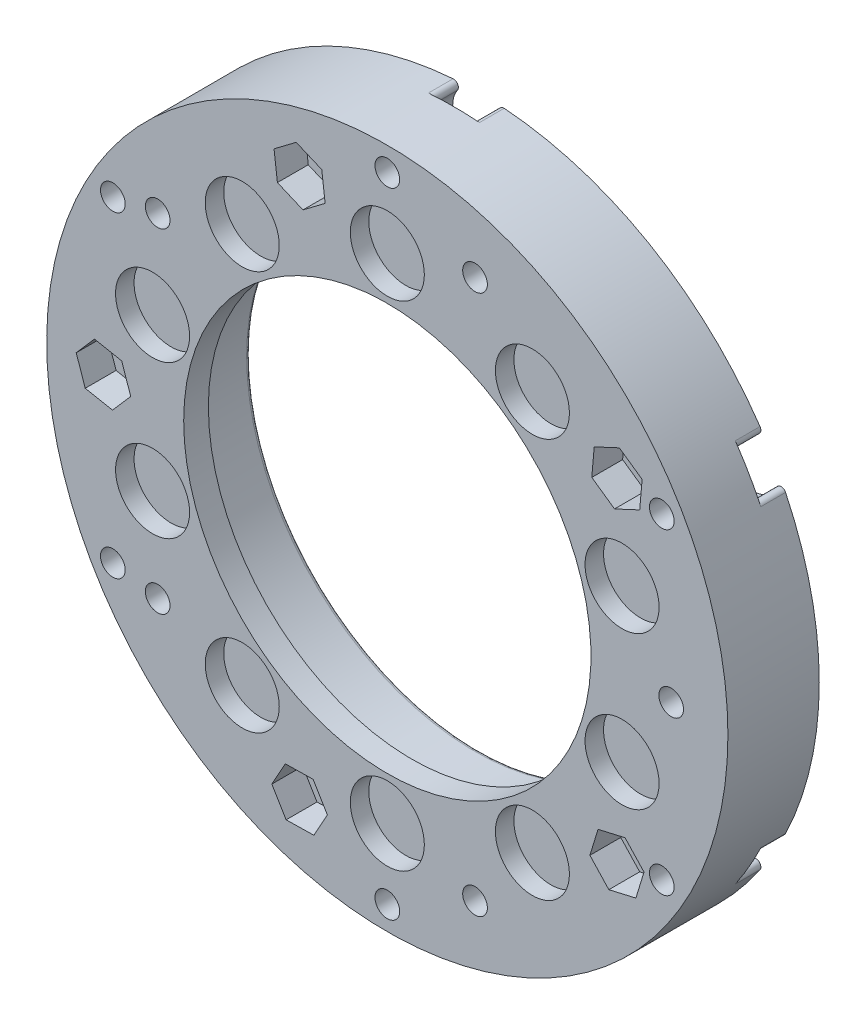
from build123d import *

# Parameters (mm, degrees)
SKETCH_1_R                = 27.6
EXTRUDE_1_DEPTH           = 5.5
SKETCH_2_R                = 3
CUT_EXTRUDE_1_DEPTH       = 1.5
SKETCH_5_R                = 18.5
CUT_EXTRUDE_3_DEPTH       = 3.5
SKETCH_7_R                = 16.5
CUT_EXTRUDE_8_DEPTH       = 4.5
CUT_EXTRUDE_8_DEPTH_BACK  = 3
SKETCH_8_R                = 27.6
SKETCH_8_R_2              = 18.5
EXTRUDE_3_DEPTH           = 0.5
SKETCH_9_R                = 1
CUT_EXTRUDE_9_DEPTH       = 1
CUT_EXTRUDE_9_DEPTH_BACK  = 7
SKETCH_10_R               = 27.6
SKETCH_10_R_2             = 18.5
SKETCH_10_R_3             = 1
EXTRUDE_4_DEPTH           = 1.4
SKETCH_11_R               = 1
EXTRUDE_5_DEPTH           = 7.4
SKETCH_12_R               = 1
CUT_EXTRUDE_10_DEPTH      = 8.4
CUT_EXTRUDE_11_DEPTH      = 2
SKETCH_15_R               = 1
CUT_EXTRUDE_12_DEPTH      = 3
CUT_EXTRUDE_12_DEPTH_BACK = 6.4
SKETCH_16_R               = 1
CUT_EXTRUDE_13_DEPTH      = 1
CUT_EXTRUDE_13_DEPTH_BACK = 8.4
SKETCH_18_R               = 1
EXTRUDE_6_DEPTH           = 2
CUT_EXTRUDE_15_DEPTH      = 2.5
SKETCH_20_R               = 2.1
CUT_EXTRUDE_16_DEPTH      = 2
FILLET_2_R                = 0.4
SKETCH_21_R               = 1.9
CUT_EXTRUDE_17_DEPTH      = 2
FILLET_3_R                = 0.3
FILLET_4_R                = 0.3


with BuildPart() as part:
    # 草图1 → 凸台-拉伸1 (new body)
    with BuildSketch(Plane.XY):
        Circle(SKETCH_1_R)
    extrude(amount=EXTRUDE_1_DEPTH)

    # 草图2 → 切除-拉伸1 (cut)
    with BuildSketch(Plane.XY.offset(5.5)):
        with Locations((0, 20)):
            Circle(SKETCH_2_R)
        with Locations((11.755705046, 16.180339887)):
            Circle(SKETCH_2_R)
        with Locations((19.021130326, 6.180339887)):
            Circle(SKETCH_2_R)
        with Locations((19.021130326, -6.180339887)):
            Circle(SKETCH_2_R)
        with Locations((11.755705046, -16.180339887)):
            Circle(SKETCH_2_R)
        with Locations((0, -20)):
            Circle(SKETCH_2_R)
        with Locations((-11.755705046, -16.180339887)):
            Circle(SKETCH_2_R)
        with Locations((-19.021130326, -6.180339887)):
            Circle(SKETCH_2_R)
        with Locations((-19.021130326, 6.180339887)):
            Circle(SKETCH_2_R)
        with Locations((-11.755705046, 16.180339887)):
            Circle(SKETCH_2_R)
    extrude(amount=-CUT_EXTRUDE_1_DEPTH, mode=Mode.SUBTRACT)

    # 草图5 → 切除-拉伸3 (cut)
    with BuildSketch(Plane(origin=(0, 0, 0), x_dir=(-1, 0, 0), z_dir=(0, 0, -1))):
        Circle(SKETCH_5_R)
    extrude(amount=-CUT_EXTRUDE_3_DEPTH, mode=Mode.SUBTRACT)

    # 草图7 → 切除-拉伸8 (cut, two sides)
    with BuildSketch(Plane(origin=(0, 0, 3.5), x_dir=(-1, 0, 0), z_dir=(0, 0, -1))) as cut_extrude_8_sk:
        Circle(SKETCH_7_R)
    extrude(amount=CUT_EXTRUDE_8_DEPTH, mode=Mode.SUBTRACT)
    extrude(cut_extrude_8_sk.sketch, amount=-CUT_EXTRUDE_8_DEPTH_BACK, mode=Mode.SUBTRACT)

    # 草图8 → 凸台-拉伸3 (add)
    with BuildSketch(Plane(origin=(0, 0, 0), x_dir=(-1, 0, 0), z_dir=(0, 0, -1))):
        Circle(SKETCH_8_R)
        Circle(SKETCH_8_R_2, mode=Mode.SUBTRACT)
    extrude(amount=EXTRUDE_3_DEPTH)

    # 草图9 → 切除-拉伸9 (cut, two sides)
    with BuildSketch(Plane.XY.offset(5.5)) as cut_extrude_9_sk:
        with Locations((8.546820623, 24.215991766)):
            Circle(SKETCH_9_R)
        with Locations((25.245074359, 4.706232102)):
            Circle(SKETCH_9_R)
        with Locations((16.698253736, -19.509759665)):
            Circle(SKETCH_9_R)
        with Locations((-8.546820623, -24.215991766)):
            Circle(SKETCH_9_R)
        with Locations((-25.245074359, -4.706232102)):
            Circle(SKETCH_9_R)
        with Locations((-16.698253736, 19.509759665)):
            Circle(SKETCH_9_R)
    extrude(amount=CUT_EXTRUDE_9_DEPTH, mode=Mode.SUBTRACT)
    extrude(cut_extrude_9_sk.sketch, amount=-CUT_EXTRUDE_9_DEPTH_BACK, mode=Mode.SUBTRACT)

    # 草图10 → 凸台-拉伸4 (add)
    with BuildSketch(Plane(origin=(0, 0, -0.5), x_dir=(-1, 0, 0), z_dir=(0, 0, -1))):
        Circle(SKETCH_10_R)
        Circle(SKETCH_10_R_2, mode=Mode.SUBTRACT)
        with Locations((-8.546820623, 24.215991766)):
            Circle(SKETCH_10_R_3, mode=Mode.SUBTRACT)
        with Locations((16.698253736, 19.509759665)):
            Circle(SKETCH_10_R_3, mode=Mode.SUBTRACT)
        with Locations((25.245074359, -4.706232102)):
            Circle(SKETCH_10_R_3, mode=Mode.SUBTRACT)
        with Locations((8.546820623, -24.215991766)):
            Circle(SKETCH_10_R_3, mode=Mode.SUBTRACT)
        with Locations((-16.698253736, -19.509759665)):
            Circle(SKETCH_10_R_3, mode=Mode.SUBTRACT)
        with Locations((-25.245074359, 4.706232102)):
            Circle(SKETCH_10_R_3, mode=Mode.SUBTRACT)
    extrude(amount=EXTRUDE_4_DEPTH)

    # 草图11 → 凸台-拉伸5 (add)
    with BuildSketch(Plane.XY.offset(5.5)):
        with Locations((8.546820623, 24.215991766)):
            Circle(SKETCH_11_R)
        with Locations((25.245074359, 4.706232102)):
            Circle(SKETCH_11_R)
        with Locations((16.698253736, -19.509759665)):
            Circle(SKETCH_11_R)
        with Locations((-8.546820623, -24.215991766)):
            Circle(SKETCH_11_R)
        with Locations((-25.245074359, -4.706232102)):
            Circle(SKETCH_11_R)
        with Locations((-16.698253736, 19.509759665)):
            Circle(SKETCH_11_R)
    extrude(amount=-EXTRUDE_5_DEPTH)

    # 草图12 → 切除-拉伸10 (cut, through all)
    with BuildSketch(Plane.XY.offset(5.5)):
        with Locations((0, 25.68)):
            Circle(SKETCH_12_R)
        with Locations((22.239532369, 12.84)):
            Circle(SKETCH_12_R)
        with Locations((22.239532369, -12.84)):
            Circle(SKETCH_12_R)
        with Locations((0, -25.68)):
            Circle(SKETCH_12_R)
        with Locations((-22.239532369, -12.84)):
            Circle(SKETCH_12_R)
        with Locations((-22.239532369, 12.84)):
            Circle(SKETCH_12_R)
    extrude(amount=-CUT_EXTRUDE_10_DEPTH, mode=Mode.SUBTRACT)

    # 草图13 → 切除-拉伸11 (cut)
    with BuildSketch(Plane.XY.offset(5.5)):
        Polygon((7.107390871, 24.124299875), (9.055948029, 22.999299875), (9.055948029, 20.749299875), (7.107390871, 19.624299875), (5.158833712, 20.749299875), (5.158833712, 22.999299875), align=None)
        Polygon((23.467801304, 2.200832102), (25.139877162, 0.695288237), (24.672075857, -1.505543864), (22.532198696, -2.200832102), (20.860122838, -0.695288237), (21.327924143, 1.505543864), align=None)
        Polygon((9.345065135, -21.639110832), (8.429907688, -23.694588112), (6.192233424, -23.929777154), (4.869716606, -22.109488917), (5.784874053, -20.054011637), (8.022548318, -19.818822595), align=None)
        Polygon((-17.692233424, -15.574538082), (-19.929907688, -15.33934904), (-20.845065135, -13.28387176), (-19.522548318, -11.463583523), (-17.284874053, -11.698772565), (-16.369716606, -13.754249845), align=None)
        Polygon((-20.279466728, 12.013516938), (-20.747268032, 14.21434904), (-19.075192175, 15.719892904), (-16.935315013, 15.024604667), (-16.467513709, 12.823772565), (-18.139589566, 11.318228701), align=None)
    extrude(amount=-CUT_EXTRUDE_11_DEPTH, mode=Mode.SUBTRACT)

    # 草图15 → 切除-拉伸12 (cut, two sides)
    with BuildSketch(Plane.XY.offset(3.5)) as cut_extrude_12_sk:
        with Locations((-18.607390871, 13.519060803)):
            Circle(SKETCH_15_R)
        with Locations((7.107390871, 21.874299875)):
            Circle(SKETCH_15_R)
        with Locations((23, 0)):
            Circle(SKETCH_15_R)
        with Locations((7.107390871, -21.874299875)):
            Circle(SKETCH_15_R)
        with Locations((-18.607390871, -13.519060803)):
            Circle(SKETCH_15_R)
    extrude(amount=CUT_EXTRUDE_12_DEPTH, mode=Mode.SUBTRACT)
    extrude(cut_extrude_12_sk.sketch, amount=-CUT_EXTRUDE_12_DEPTH_BACK, mode=Mode.SUBTRACT)

    # 草图16 → 切除-拉伸13 (cut, two sides)
    with BuildSketch(Plane.XY.offset(5.5)) as cut_extrude_13_sk:
        with Locations((-7.107390871, 21.874299875)):
            Circle(SKETCH_16_R)
        with Locations((18.607390871, 13.519060803)):
            Circle(SKETCH_16_R)
        with Locations((18.607390871, -13.519060803)):
            Circle(SKETCH_16_R)
        with Locations((-7.107390871, -21.874299875)):
            Circle(SKETCH_16_R)
        with Locations((-23, 0)):
            Circle(SKETCH_16_R)
    extrude(amount=CUT_EXTRUDE_13_DEPTH, mode=Mode.SUBTRACT)
    extrude(cut_extrude_13_sk.sketch, amount=-CUT_EXTRUDE_13_DEPTH_BACK, mode=Mode.SUBTRACT)

    # 草图18 → 凸台-拉伸6 (add)
    with BuildSketch(Plane.XY.offset(5.5)):
        Polygon((7.107390871, 24.124299875), (9.055948029, 22.999299875), (9.055948029, 20.749299875), (7.107390871, 19.624299875), (5.158833712, 20.749299875), (5.158833712, 22.999299875), align=None)
        with Locations((7.107390871, 21.874299875)):
            Circle(SKETCH_18_R, mode=Mode.SUBTRACT)
        Polygon((23.467801304, 2.200832102), (25.139877162, 0.695288237), (24.672075857, -1.505543864), (22.532198696, -2.200832102), (20.860122838, -0.695288237), (21.327924143, 1.505543864), align=None)
        with Locations((23, 0)):
            Circle(SKETCH_18_R, mode=Mode.SUBTRACT)
        Polygon((9.345065135, -21.639110832), (8.429907688, -23.694588112), (6.192233424, -23.929777154), (4.869716606, -22.109488917), (5.784874053, -20.054011637), (8.022548318, -19.818822595), align=None)
        with Locations((7.107390871, -21.874299875)):
            Circle(SKETCH_18_R, mode=Mode.SUBTRACT)
        Polygon((-17.692233424, -15.574538082), (-19.929907688, -15.33934904), (-20.845065135, -13.28387176), (-19.522548318, -11.463583523), (-17.284874053, -11.698772565), (-16.369716606, -13.754249845), align=None)
        with Locations((-18.607390871, -13.519060803)):
            Circle(SKETCH_18_R, mode=Mode.SUBTRACT)
        Polygon((-20.279466728, 12.013516938), (-20.747268032, 14.21434904), (-19.075192175, 15.719892904), (-16.935315013, 15.024604667), (-16.467513709, 12.823772565), (-18.139589566, 11.318228701), align=None)
        with Locations((-18.607390871, 13.519060803)):
            Circle(SKETCH_18_R, mode=Mode.SUBTRACT)
    extrude(amount=-EXTRUDE_6_DEPTH)

    # 草图19 → 切除-拉伸15 (cut)
    with BuildSketch(Plane.XY.offset(5.5)):
        Polygon((-8.90428805, 20.520172655), (-9.178548032, 22.75339487), (-7.381650853, 24.10752209), (-5.310493691, 23.228427094), (-5.036233709, 20.995204879), (-6.833130888, 19.64107766), align=None)
        Polygon((16.568221326, 12.568120442), (16.764267589, 14.809563251), (18.803437133, 15.760503611), (20.646560415, 14.470001163), (20.450514152, 12.228558355), (18.411344608, 11.277617994), align=None)
        Polygon((17.072854801, -11.873552052), (19.265175216, -11.367359208), (20.799711286, -13.012867959), (20.141926941, -15.164569554), (17.949606525, -15.670762398), (16.415070455, -14.025253647), align=None)
        Polygon((-6.016616774, -19.906379178), (-4.857734506, -21.834977603), (-5.948508602, -23.802898301), (-8.198164967, -23.842220572), (-9.357047235, -21.913622146), (-8.266273139, -19.945701449), align=None)
        Polygon((-20.791328465, -0.429266873), (-22.267420249, -2.127399095), (-24.476091785, -1.698132222), (-25.208671535, 0.429266873), (-23.732579751, 2.127399095), (-21.523908215, 1.698132222), align=None)
    extrude(amount=-CUT_EXTRUDE_15_DEPTH, mode=Mode.SUBTRACT)

    # 草图20 → 切除-拉伸16 (cut)
    with BuildSketch(Plane(origin=(0, 0, -1.9), x_dir=(-1, 0, 0), z_dir=(0, 0, -1))):
        with Locations((0, 25.68)):
            Circle(SKETCH_20_R)
        with Locations((22.239532369, 12.84)):
            Circle(SKETCH_20_R)
        with Locations((22.239532369, -12.84)):
            Circle(SKETCH_20_R)
        with Locations((0, -25.68)):
            Circle(SKETCH_20_R)
        with Locations((-22.239532369, -12.84)):
            Circle(SKETCH_20_R)
        with Locations((-22.239532369, 12.84)):
            Circle(SKETCH_20_R)
    extrude(amount=-CUT_EXTRUDE_16_DEPTH, mode=Mode.SUBTRACT)

    # 圆角2
    fillet_2_edges = [part.edges().sort_by_distance(p)[0] for p in [
        (0.881760988, 27.585911215, -0.95),
        (-0.881760988, 27.585911215, -0.95),
        (24.330980393, 13.029328191, -0.95),
        (23.449219404, 14.556583024, -0.95),
        (23.449219404, -14.556583024, -0.9),
        (24.330980393, -13.029328191, -0.9),
        (-0.881760988, -27.585911215, -0.9),
        (0.881760988, -27.585911215, -0.9),
        (-24.330980393, -13.029328191, -0.9),
        (-23.449219404, -14.556583024, -0.9),
        (-23.449219404, 14.556583024, -0.95),
        (-24.330980393, 13.029328191, -0.95),
    ]]
    fillet(fillet_2_edges, radius=FILLET_2_R)

    # 草图21 → 切除-拉伸17 (cut)
    with BuildSketch(Plane(origin=(0, 0, -1.9), x_dir=(-1, 0, 0), z_dir=(0, 0, -1))):
        with Locations((18.607390871, 13.519060803)):
            Circle(SKETCH_21_R)
        with Locations((18.607390871, -13.519060803)):
            Circle(SKETCH_21_R)
        with Locations((-7.107390871, -21.874299875)):
            Circle(SKETCH_21_R)
        with Locations((-23, 0)):
            Circle(SKETCH_21_R)
        with Locations((-7.107390871, 21.874299875)):
            Circle(SKETCH_21_R)
    extrude(amount=-CUT_EXTRUDE_17_DEPTH, mode=Mode.SUBTRACT)

    # 圆角3
    fillet_3_edges = [part.edges().sort_by_distance(p)[0] for p in [
        (-20.457600141, -13.951178444, -0.9),
        (-20.176506082, -12.447670372, -0.9),
        (-20.176506082, 12.447670372, -0.9),
        (-20.457600141, 13.951178444, -0.9),
    ]]
    fillet(fillet_3_edges, radius=FILLET_3_R)

    # 圆角4
    fillet_4_edges = [part.edges().sort_by_distance(p)[0] for p in [
        (18.5, 0, -1.9),
    ]]
    fillet(fillet_4_edges, radius=FILLET_4_R)


solid = part.part
